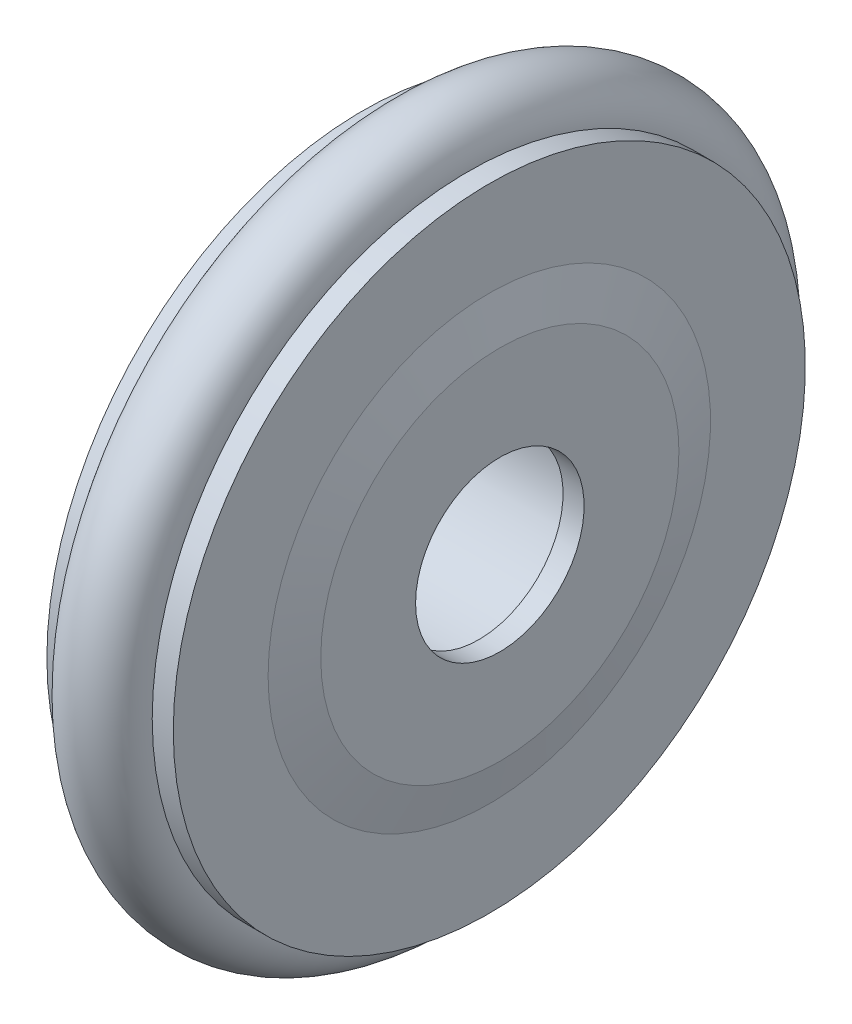
from build123d import *

# Parameters (mm, degrees)
SKETCH_1_R = 1.95


with BuildPart() as part:
    # 草图1 → 旋转1 (revolve)
    with BuildSketch(Plane.XY):
        with Locations((3, 15)):
            Circle(SKETCH_1_R)
        with BuildLine():
            Line((5.5, 5.1), (5.5, 4))
            Line((5.5, 4), (6.5, 4))
            Line((6.5, 4), (6.5, 8.5))
            Line((6.5, 8.5), (6, 10.5))
            Line((6, 10.5), (6, 15))
            Line((6, 15), (5, 15))
            ThreePointArc((5, 15), (3, 13), (1, 15))
            Line((1, 15), (0, 15))
            Line((0, 15), (0, 5.1))
            Line((0, 5.1), (5.5, 5.1))
        make_face()
    revolve(axis=Axis((0, 0, 0), (1, 0, 0)))


solid = part.part
